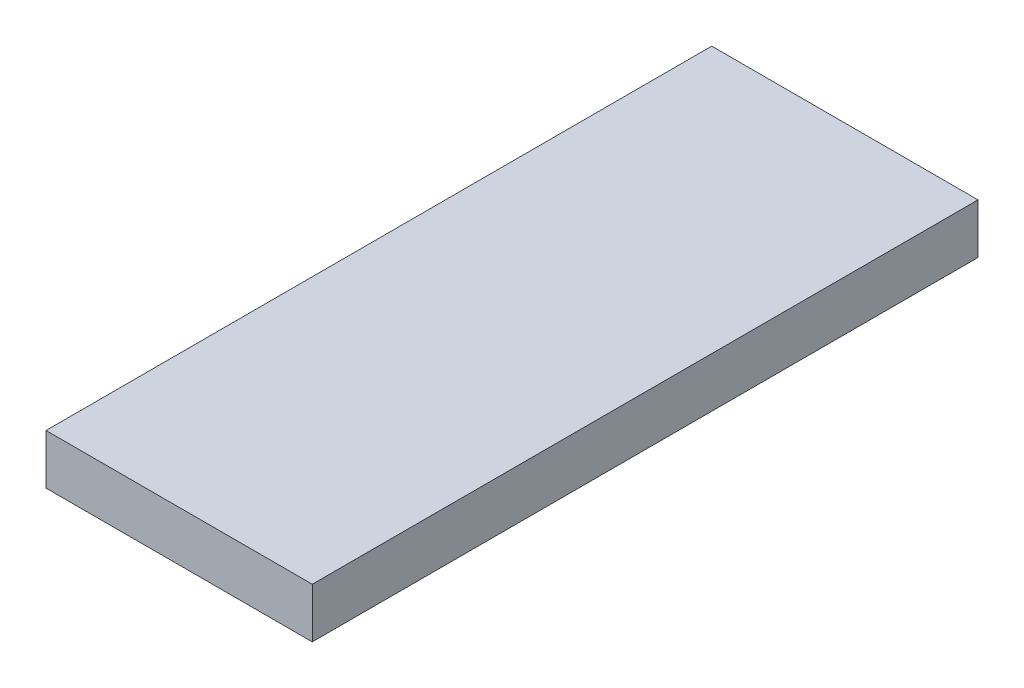
from build123d import *

# Parameters (mm, degrees)
SKETCH_1_W      = 16
SKETCH_1_H      = 40
EXTRUDE_1_DEPTH = 3


with BuildPart() as part:
    # 草图1 → 凸台-拉伸1 (new body)
    with BuildSketch(Plane(origin=(0, 0, 0), x_dir=(1, 0, 0), z_dir=(0, 1, 0))):
        Rectangle(SKETCH_1_W, SKETCH_1_H)
    extrude(amount=EXTRUDE_1_DEPTH)


solid = part.part
